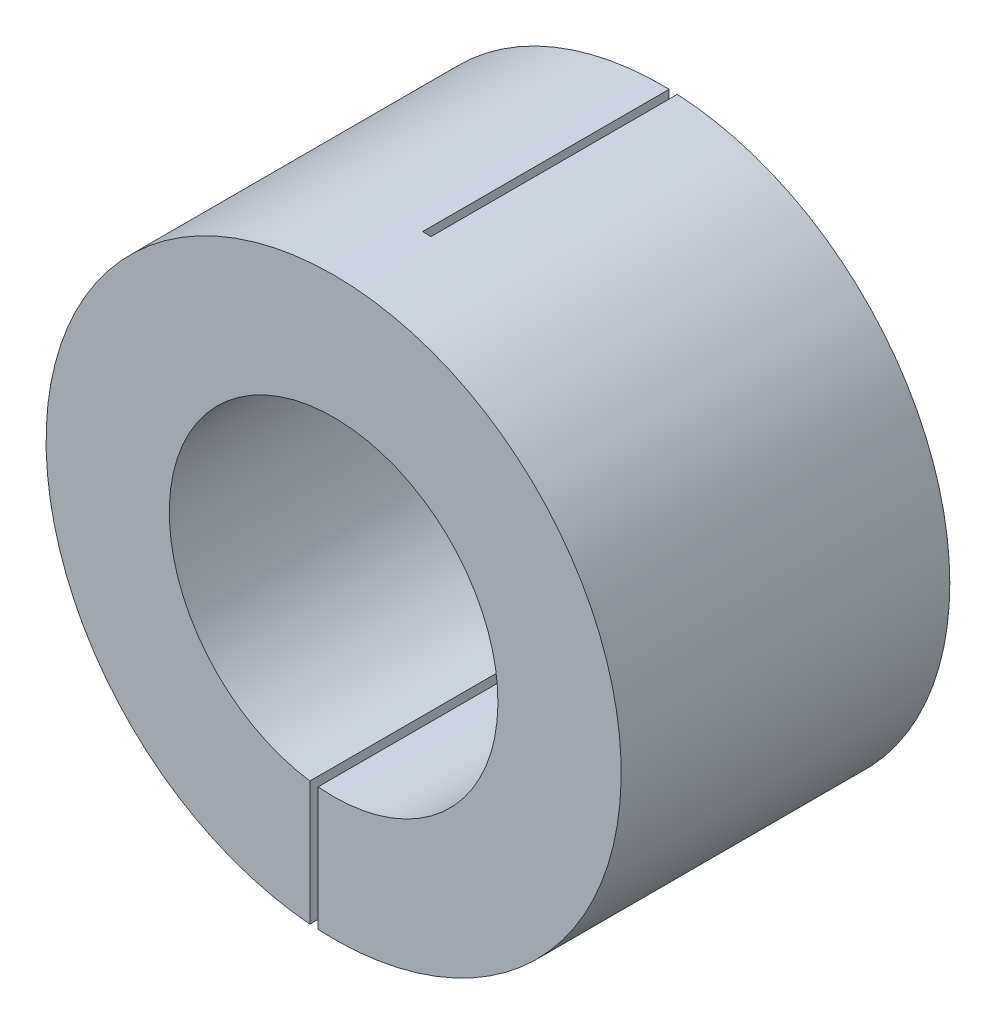
from build123d import *

# Parameters (mm, degrees)
SKETCH_1_R          = 17.5
SKETCH_1_R_2        = 10
EXTRUDE_1_DEPTH     = 20
SKETCH_2_W          = 0.5
SKETCH_2_H          = 19.301562603
CUT_EXTRUDE_1_DEPTH = 15
SKETCH_3_W          = 0.5
SKETCH_3_H          = 20.813345434
CUT_EXTRUDE_2_DEPTH = 15


with BuildPart() as part:
    # 草图1 → 凸台-拉伸1 (new body)
    with BuildSketch(Plane.XY):
        Circle(SKETCH_1_R)
        Circle(SKETCH_1_R_2, mode=Mode.SUBTRACT)
    extrude(amount=EXTRUDE_1_DEPTH)

    # 草图2 → 切除-拉伸1 (cut)
    with BuildSketch(Plane.XY.offset(20)):
        with Locations((-1.195478964, -9.928284345)):
            Rectangle(SKETCH_2_W, SKETCH_2_H)
    extrude(amount=-CUT_EXTRUDE_1_DEPTH, mode=Mode.SUBTRACT)

    # 草图3 → 切除-拉伸2 (cut)
    with BuildSketch(Plane(origin=(0, 0, 0), x_dir=(-1, 0, 0), z_dir=(0, 0, -1))):
        with Locations((-0.669659449, 7.720299062)):
            Rectangle(SKETCH_3_W, SKETCH_3_H)
    extrude(amount=-CUT_EXTRUDE_2_DEPTH, mode=Mode.SUBTRACT)


solid = part.part
